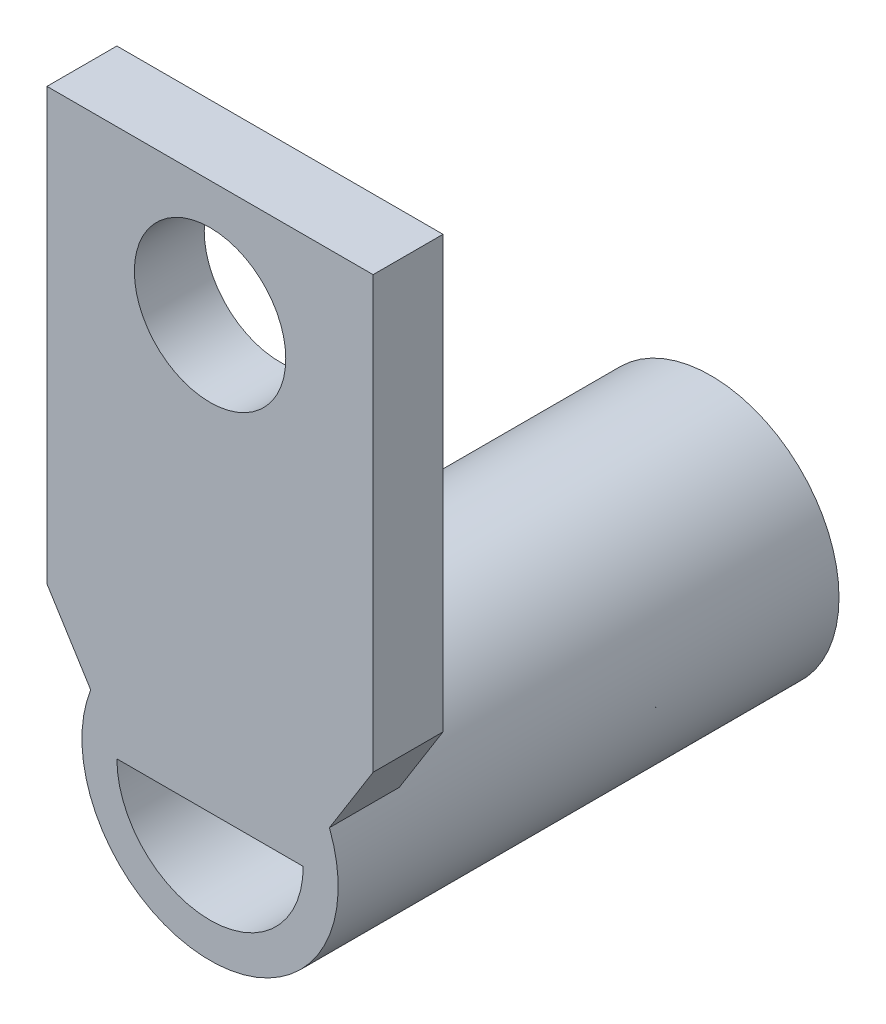
from build123d import *

# Parameters (mm, degrees)
SKETCH_1_R          = 5.5
SKETCH_1_R_2        = 4
EXTRUDE_1_DEPTH     = 21.5
SKETCH_2_W          = 14
SKETCH_2_H          = 3
EXTRUDE_2_DEPTH     = 23.5
SKETCH_3_R          = 3.25
CUT_EXTRUDE_1_DEPTH = 10


with BuildPart() as part:
    # 草图1 → 凸台-拉伸1 (new body)
    with BuildSketch(Plane.XY):
        Circle(SKETCH_1_R)
        Circle(SKETCH_1_R_2, mode=Mode.SUBTRACT)
    extrude(amount=EXTRUDE_1_DEPTH)

    # 草图2 → 凸台-拉伸2 (add)
    with BuildSketch(Plane(origin=(0, 0, 0), x_dir=(1, 0, 0), z_dir=(0, 1, 0))):
        with Locations((0, -20)):
            Rectangle(SKETCH_2_W, SKETCH_2_H)
    extrude(amount=EXTRUDE_2_DEPTH)

    # 草图3 → 切除-拉伸1 (cut)
    with BuildSketch(Plane(origin=(0, 0, 18.5), x_dir=(-1, 0, 0), z_dir=(0, 0, -1))):
        with Locations((0, 18.5)):
            Circle(SKETCH_3_R)
        with BuildLine():
            Line((-5.123475383, 2), (-7, 5))
            Line((-7, 5), (-7, 0))
            Line((-7, 0), (-5.5, 0))
            ThreePointArc((-5.5, 0), (-5.405049242, 1.017567048), (-5.123475383, 2))
        make_face()
        with BuildLine():
            Line((7, 5), (5.123475383, 2))
            ThreePointArc((5.123475383, 2), (5.405049242, 1.017567048), (5.5, 0))
            Line((5.5, 0), (7, 0))
            Line((7, 0), (7, 5))
        make_face()
    extrude(amount=-CUT_EXTRUDE_1_DEPTH, mode=Mode.SUBTRACT)


solid = part.part
